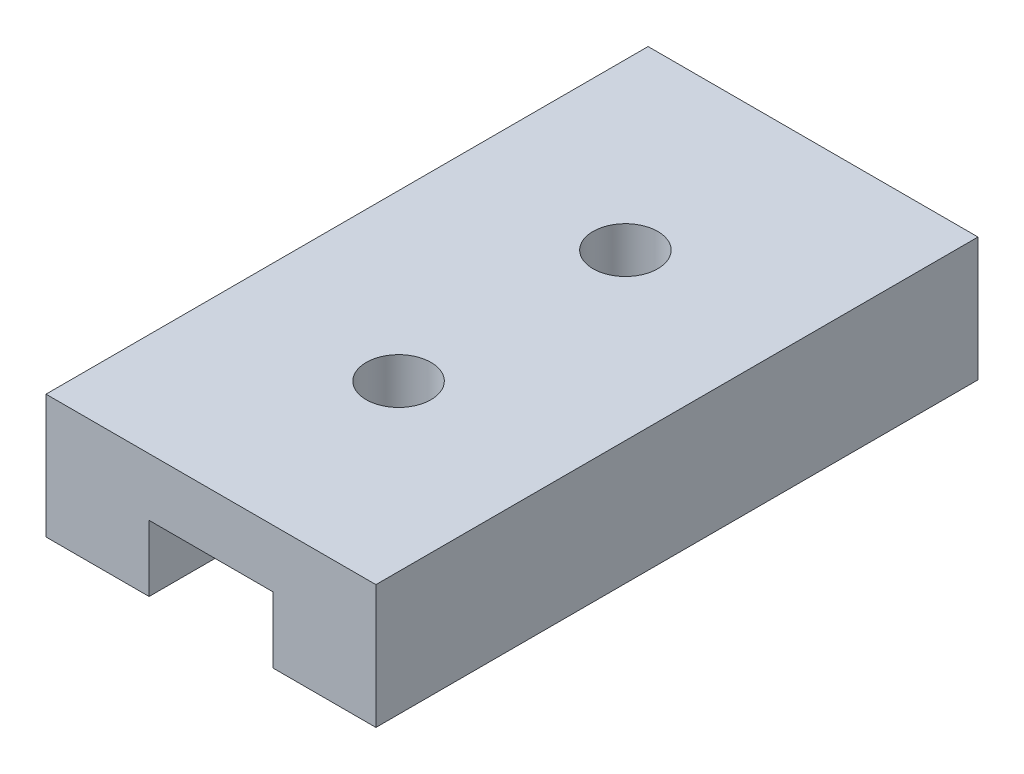
from build123d import *

# Parameters (mm, degrees)
BOSS_EXTRUDE1_DEPTH = 14.6
SKETCH2_R           = 0.785
CUT_EXTRUDE1_DEPTH  = 4


with BuildPart() as part:
    # Sketch1 → Boss-Extrude1 (new body)
    with BuildSketch(Plane.XY):
        Polygon((-1.5, 0), (-4, 0), (-4, 3), (4, 3), (4, 0), (1.5, 0), (1.5, 1.6), (-1.5, 1.6), align=None)
    extrude(amount=BOSS_EXTRUDE1_DEPTH)

    # Sketch2 → Cut-Extrude1 (cut, through all)
    with BuildSketch(Plane(origin=(0, 3, 0), x_dir=(1, 0, 0), z_dir=(0, 1, 0))):
        with Locations((0, -10.05)):
            Circle(SKETCH2_R)
        with Locations((0, -4.55)):
            Circle(SKETCH2_R)
    extrude(amount=-CUT_EXTRUDE1_DEPTH, mode=Mode.SUBTRACT)


solid = part.part
